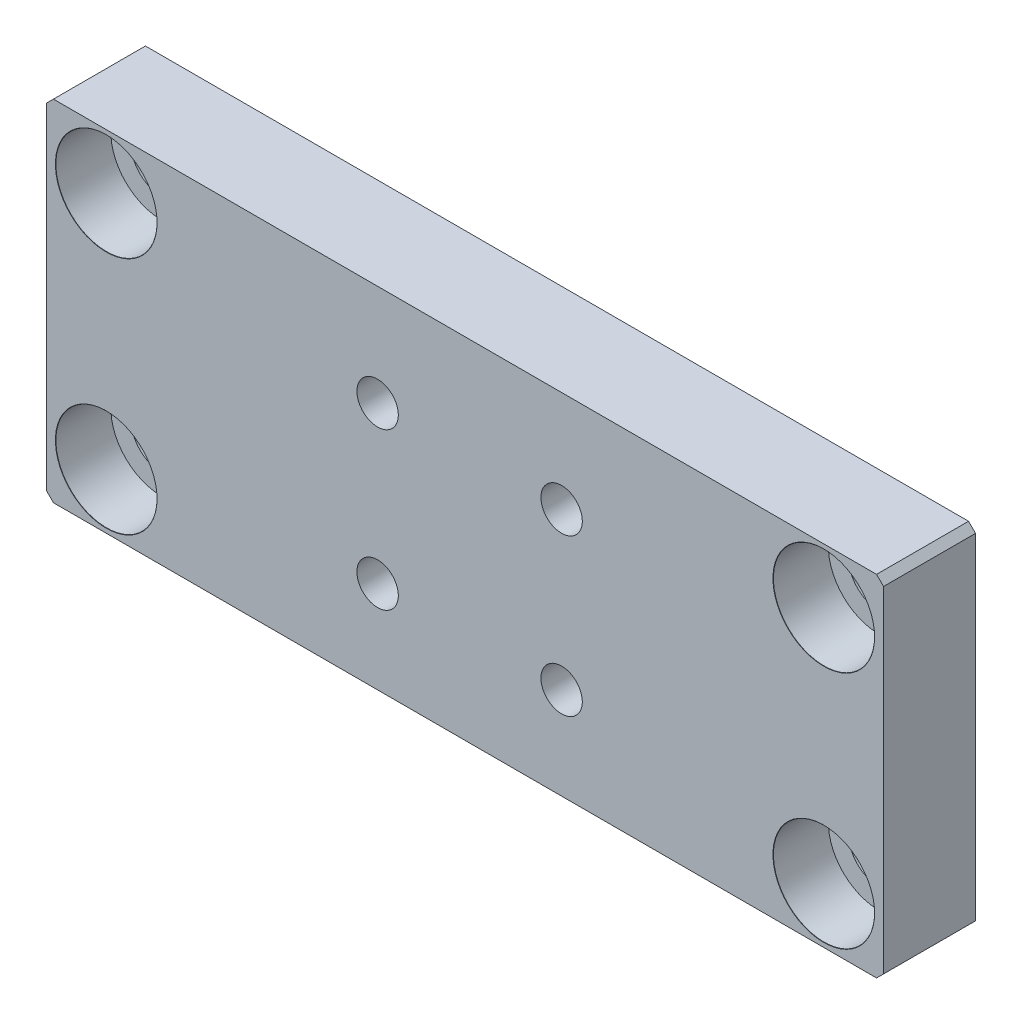
from build123d import *

# Parameters (mm, degrees)
BOSS_EXTRUDE1_DEPTH  = 10
LPATTERN2_COUNT      = 2
LPATTERN2_PITCH      = 78
LPATTERN2_COUNT_DIR2 = 2
LPATTERN2_PITCH_DIR2 = 26
LPATTERN3_COUNT      = 2
LPATTERN3_PITCH      = 20
LPATTERN3_COUNT_DIR2 = 2
LPATTERN3_PITCH_DIR2 = 17


with BuildPart() as part:
    # Sketch1 → Boss-Extrude1 (new body)
    with BuildSketch(Plane.XY):
        Polygon((92.000001103, 39.239999717), (91.240001103, 39.999999717), (1.760001103, 39.999999717), (1.000001103, 39.239999717), (1.000001103, 2.759999717), (1.760001103, 1.999999717), (91.240001103, 1.999999717), (92.000001103, 2.759999717), align=None)
    extrude(amount=BOSS_EXTRUDE1_DEPTH)

    # Sketch4 → CBORE for M6 SHCS1 (revolve, cut)
    with BuildSketch(Plane(origin=(7.500001103, 33.999999717, 10), x_dir=(0, -1, 0), z_dir=(1, 0, 0))):
        Polygon((0, 0), (0, 10), (3.3, 10), (3.3, 6), (5.5, 6), (5.5, 0.025), (5.525, 0), align=None)
    cbore_for_m6_shcs1 = revolve(axis=Axis((7.500001103, 33.999999717, 16.35), (0, 0, -1)), mode=Mode.SUBTRACT)

    # LPattern2: CBORE for M6 SHCS1 2 × 2
    with Locations(*[(i * LPATTERN2_PITCH, -j * LPATTERN2_PITCH_DIR2, 0) for i in range(LPATTERN2_COUNT) for j in range(LPATTERN2_COUNT_DIR2) if (i, j) != (0, 0)]):
        add(cbore_for_m6_shcs1, mode=Mode.SUBTRACT)

    # Sketch6 → CBORE for M4 SHCS1 (revolve, cut)
    with BuildSketch(Plane(origin=(57.000001103, 11.999999717, 0), x_dir=(0, 1, 0), z_dir=(1, 0, 0))):
        Polygon((0, 0), (0, 10), (2.25, 10), (2.25, 4), (4, 4), (4, 0.025), (4.025, 0), align=None)
    cbore_for_m4_shcs1 = revolve(axis=Axis((57.000001103, 11.999999717, -6.35), (0, 0, 1)), mode=Mode.SUBTRACT)

    # LPattern3: CBORE for M4 SHCS1 2 × 2
    with Locations(*[(-i * LPATTERN3_PITCH, j * LPATTERN3_PITCH_DIR2, 0) for i in range(LPATTERN3_COUNT) for j in range(LPATTERN3_COUNT_DIR2) if (i, j) != (0, 0)]):
        add(cbore_for_m4_shcs1, mode=Mode.SUBTRACT)


solid = part.part
